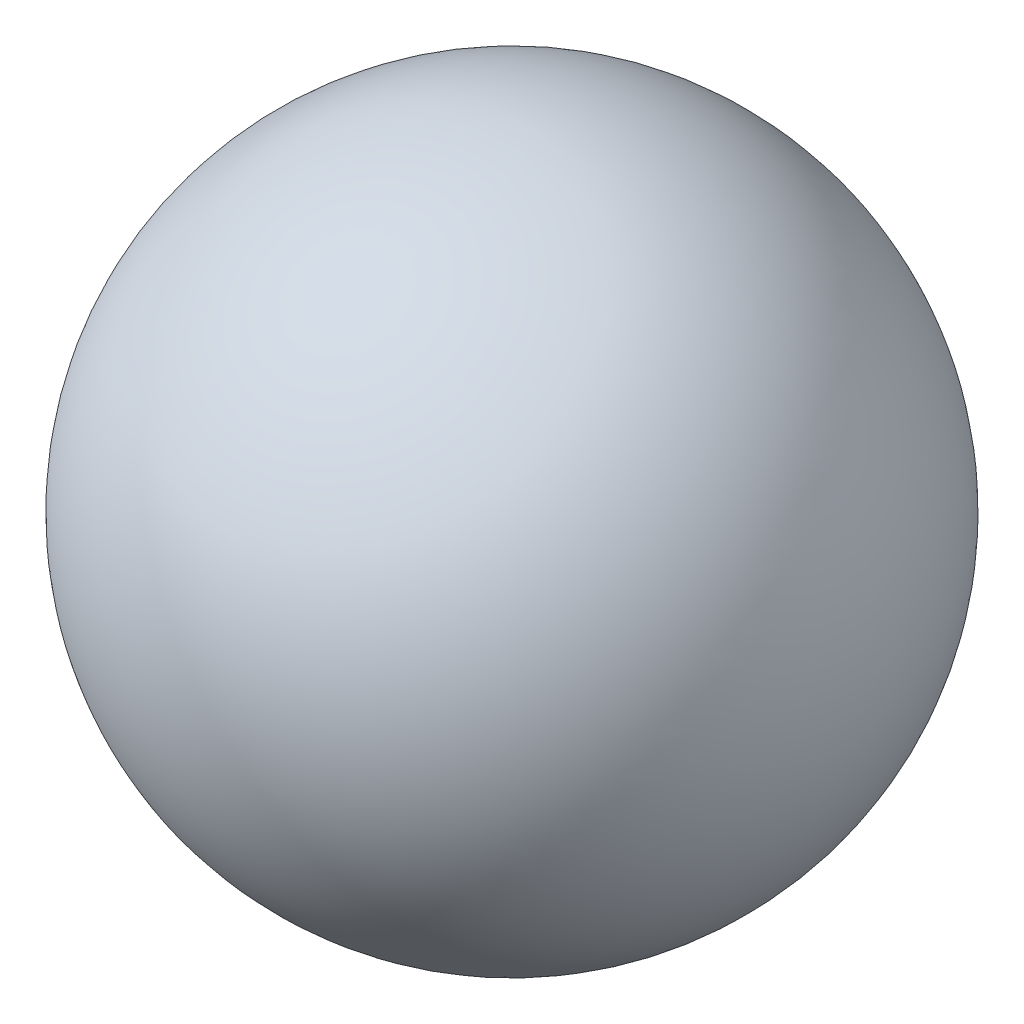
from build123d import *


with BuildPart() as part:
    # 草图1 one side → 旋转2 (revolve)
    with BuildSketch(Plane(origin=(0, 0, 0), x_dir=(1, 0, 0), z_dir=(0, 1, 0))):
        with BuildLine():
            ThreePointArc((0, -2), (1.414213562, -1.414213562), (2, 0))
            ThreePointArc((2, 0), (1.414213562, 1.414213562), (0, 2))
            Line((0, 2), (0, -2))
        make_face()
    revolve(axis=Axis((0, 0, -6.936103092), (0, 0, 1)))


solid = part.part
